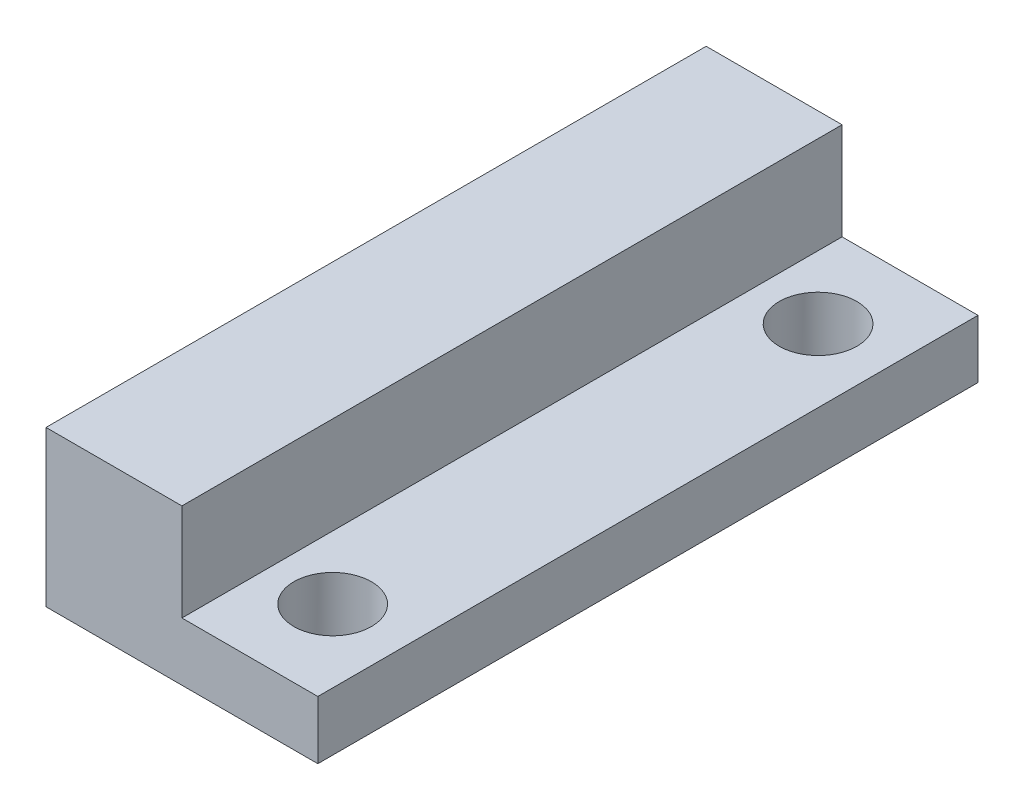
from build123d import *

# Parameters (mm, degrees)
SKETCH1_W           = 14
SKETCH1_H           = 34
BOSS_EXTRUDE1_DEPTH = 3
SKETCH2_W           = 7
SKETCH2_H           = 34
BOSS_EXTRUDE2_DEPTH = 5
SKETCH3_R           = 2
CUT_EXTRUDE1_DEPTH  = 5


with BuildPart() as part:
    # Sketch1 → Boss-Extrude1 (new body)
    with BuildSketch(Plane(origin=(0, 0, 0), x_dir=(1, 0, 0), z_dir=(0, 1, 0))):
        Rectangle(SKETCH1_W, SKETCH1_H)
    extrude(amount=BOSS_EXTRUDE1_DEPTH)

    # Sketch2 → Boss-Extrude2 (add)
    with BuildSketch(Plane(origin=(0, 3, 0), x_dir=(1, 0, 0), z_dir=(0, 1, 0))):
        with Locations((-3.5, 0)):
            Rectangle(SKETCH2_W, SKETCH2_H)
    extrude(amount=BOSS_EXTRUDE2_DEPTH)

    # Sketch3 → Cut-Extrude1 (cut)
    with BuildSketch(Plane(origin=(0, 3, 0), x_dir=(1, 0, 0), z_dir=(0, 1, 0))):
        with Locations((3.263282708, -12.5)):
            Circle(SKETCH3_R)
        with Locations((3.263282708, 12.5)):
            Circle(SKETCH3_R)
    extrude(amount=-CUT_EXTRUDE1_DEPTH, mode=Mode.SUBTRACT)


solid = part.part
